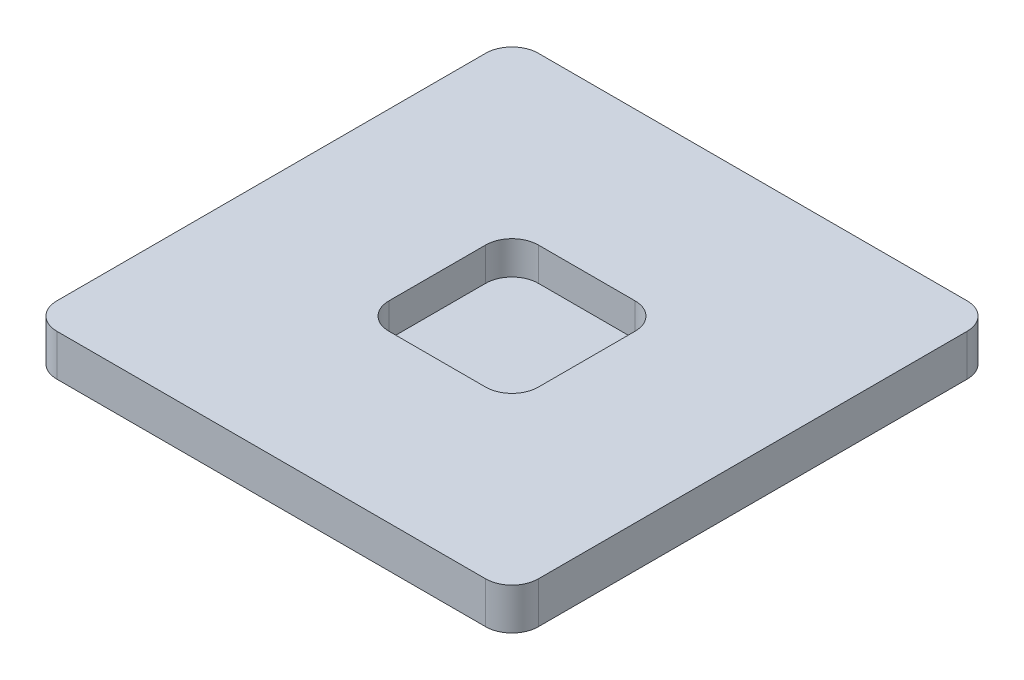
from build123d import *

# Parameters (mm, degrees)
SKETCH1_W           = 29
SKETCH1_H           = 29
BOSS_EXTRUDE1_DEPTH = 7.5
SKETCH8_W           = 9
SKETCH8_H           = 9
CUT_EXTRUDE3_DEPTH  = 2
SKETCH9_W           = 29
SKETCH9_H           = 29
SKETCH9_W_2         = 15
SKETCH9_H_2         = 15
CUT_EXTRUDE4_DEPTH  = 5
CUT_EXTRUDE5_DEPTH  = 2
FILLET1_R           = 1.5875


with BuildPart() as part:
    # Sketch1 → Boss-Extrude1 (new body)
    with BuildSketch(Plane(origin=(0, 0, 0), x_dir=(1, 0, 0), z_dir=(0, 1, 0))):
        with Locations((14.5, 14.5)):
            Rectangle(SKETCH1_W, SKETCH1_H)
    extrude(amount=BOSS_EXTRUDE1_DEPTH)

    # Sketch8 → Cut-Extrude3 (cut)
    with BuildSketch(Plane(origin=(0, 7.5, 0), x_dir=(1, 0, 0), z_dir=(0, 1, 0))):
        with Locations((14.5, 14.5)):
            Rectangle(SKETCH8_W, SKETCH8_H)
    extrude(amount=-CUT_EXTRUDE3_DEPTH, mode=Mode.SUBTRACT)

    # Sketch9 → Cut-Extrude4 (cut)
    with BuildSketch(Plane.XZ):
        with Locations((14.5, -14.5)):
            Rectangle(SKETCH9_W, SKETCH9_H)
        with Locations((14.5, -14.5)):
            Rectangle(SKETCH9_W_2, SKETCH9_H_2, mode=Mode.SUBTRACT)
    extrude(amount=-CUT_EXTRUDE4_DEPTH, mode=Mode.SUBTRACT)

    # Sketch10 → Cut-Extrude5 (cut)
    with BuildSketch(Plane.XZ):
        Polygon((12.75, -7), (16.25, -7), (16.25, -8.825378798), (20.174621202, -12.75), (22, -12.75), (22, -16.25), (20.174621202, -16.25), (16.25, -20.174621202), (16.25, -22), (12.75, -22), (12.75, -20.174621202), (8.825378798, -16.25), (7, -16.25), (7, -12.75), (8.825378798, -12.75), (12.75, -8.825378798), align=None)
    extrude(amount=-CUT_EXTRUDE5_DEPTH, mode=Mode.SUBTRACT)

    # Fillet1
    fillet1_edges = [part.edges().sort_by_distance(p)[0] for p in [
        (10, 6.5, -10),
        (10, 6.5, -19),
        (19, 6.5, -19),
        (19, 6.5, -10),
        (12.75, 1, -8.825378798),
        (16.25, 1, -8.825378798),
        (20.174621202, 1, -12.75),
        (20.174621202, 1, -16.25),
        (16.25, 1, -20.174621202),
        (12.75, 1, -20.174621202),
        (8.825378798, 1, -16.25),
        (8.825378798, 1, -12.75),
        (0, 6.25, -29),
        (29, 6.25, -29),
        (29, 6.25, 0),
        (0, 6.25, 0),
    ]]
    fillet(fillet1_edges, radius=FILLET1_R)


solid = part.part
